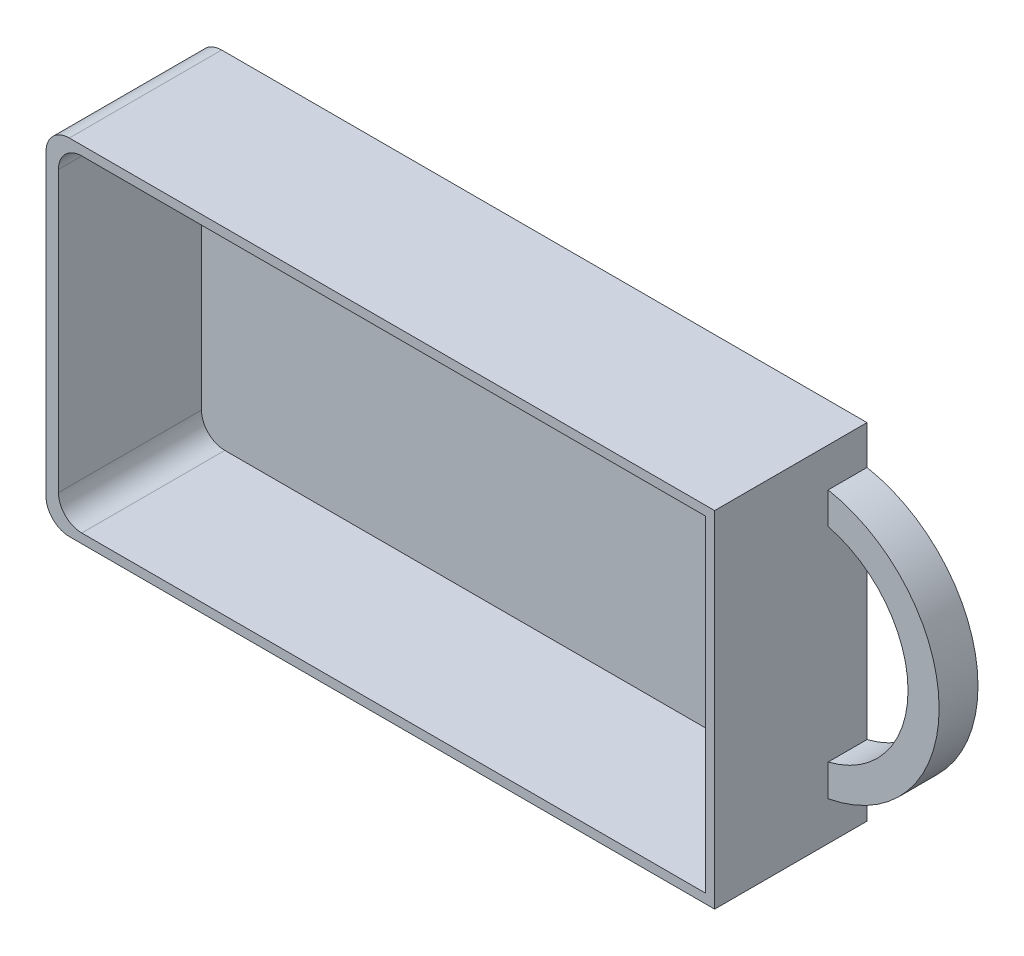
from build123d import *

# Parameters (mm, degrees)
SKETCH_1_W          = 86
SKETCH_1_H          = 44.4
EXTRUDE_1_DEPTH     = 19.6
EXTRUDE_2_DEPTH     = 5
SKETCH_3_W          = 83.2
SKETCH_3_H          = 42
CUT_EXTRUDE_1_DEPTH = 18.4
FILLET_1_R          = 3


with BuildPart() as part:
    # Эскиз1 → Бобышка-Вытянуть1 (new body)
    with BuildSketch(Plane.XY):
        Rectangle(SKETCH_1_W, SKETCH_1_H)
    extrude(amount=EXTRUDE_1_DEPTH)

    # Эскиз2 → Бобышка-Вытянуть2 (add)
    with BuildSketch(Plane.XY):
        with BuildLine():
            Line((43, 17.2), (43, 13.108775687))
            ThreePointArc((43, 13.108775687), (53.273546839, 0), (43, -13.108775687))
            Line((43, -13.108775687), (43, -17.2))
            ThreePointArc((43, -17.2), (57.273546839, 0), (43, 17.2))
        make_face()
    extrude(amount=EXTRUDE_2_DEPTH)

    # Эскиз3 → Вырез-Вытянуть1 (cut)
    with BuildSketch(Plane.XY.offset(19.6)):
        with Locations((0.2, 0)):
            Rectangle(SKETCH_3_W, SKETCH_3_H)
    extrude(amount=-CUT_EXTRUDE_1_DEPTH, mode=Mode.SUBTRACT)

    # Скругление1
    fillet_1_edges = [part.edges().sort_by_distance(p)[0] for p in [
        (-41.4, -21, 10.4),
        (-41.4, 21, 10.4),
        (-43, -22.2, 9.8),
        (-43, 22.2, 9.8),
    ]]
    fillet(fillet_1_edges, radius=FILLET_1_R)


solid = part.part
